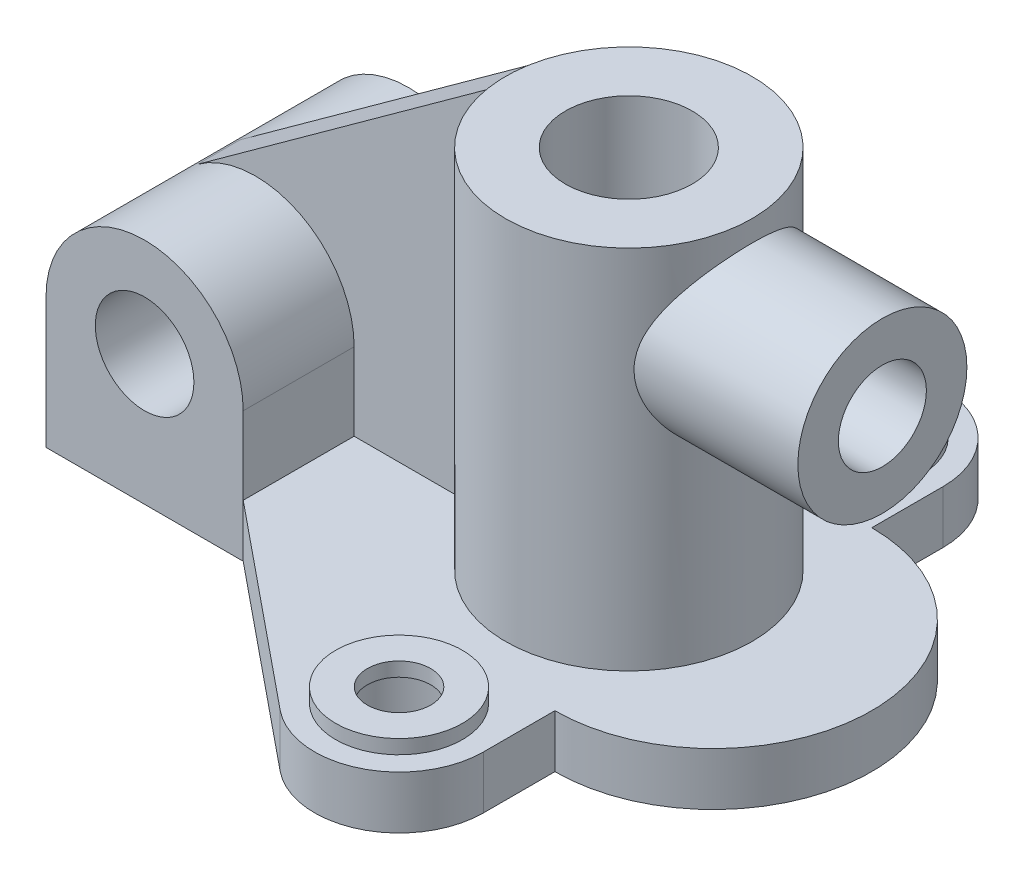
from build123d import *

# Parameters (mm, degrees)
SKETCH1_R             = 18
BOSS_EXTRUDE1_DEPTH   = 15
SKETCH2_R             = 18
SKETCH2_R_2           = 9
BOSS_EXTRUDE2_DEPTH   = 4
BOSS_EXTRUDE2_2_DEPTH = 4
SKETCH3_R             = 35
SKETCH3_R_2           = 18
BOSS_EXTRUDE3_DEPTH   = 104
SKETCH4_R             = 14
BOSS_EXTRUDE4_DEPTH   = 75
SKETCH6_R             = 24
SKETCH6_R_2           = 12.5
BOSS_EXTRUDE5_DEPTH   = 72
SKETCH9_R             = 18
CUT_EXTRUDE2_DEPTH    = 213.674418186
RIB1_REACH            = 214.674
SKETCH17_WALL_W       = 526.407388692
SKETCH17_WALL_H       = 12


with BuildPart() as part:
    # Sketch1 → Boss-Extrude1 (new body)
    with BuildSketch(Plane(origin=(0, 0, 0), x_dir=(1, 0, 0), z_dir=(0, 1, 0))):
        with BuildLine():
            Line((0, -45), (0, -65.249135293))
            ThreePointArc((0, -65.249135293), (-13.705250772, -86.929037007), (-39.168178194, -83.848231247))
            Line((-39.168178194, -83.848231247), (-96, -37.5))
            Line((-96, -37.5), (-152, -37.5))
            Line((-152, -37.5), (-152, 37.5))
            Line((-152, 37.5), (-96, 37.5))
            Line((-96, 37.5), (-39.168178194, 83.848231247))
            ThreePointArc((-39.168178194, 83.848231247), (-13.705250772, 86.929037007), (0, 65.249135293))
            Line((0, 65.249135293), (0, 45))
            ThreePointArc((0, 45), (45, 0), (0, -45))
        make_face()
        with Locations(Location((-24, 65.249135293, 0), (0, 0, 270))):
            Circle(SKETCH1_R, mode=Mode.SUBTRACT)
        with Locations(Location((-24, -65.249135293, 0), (0, 0, 270))):
            Circle(SKETCH1_R, mode=Mode.SUBTRACT)
    extrude(amount=BOSS_EXTRUDE1_DEPTH)

    # Sketch3 → Boss-Extrude3 (add)
    with BuildSketch(Plane(origin=(0, 15, 0), x_dir=(1, 0, 0), z_dir=(0, 1, 0))):
        with Locations(Location((-24, 0, 0), (0, 0, 270))):
            Circle(SKETCH3_R)
        with Locations(Location((-24, 0, 0), (0, 0, 270))):
            Circle(SKETCH3_R_2, mode=Mode.SUBTRACT)
    extrude(amount=BOSS_EXTRUDE3_DEPTH)

    # Sketch4 → Boss-Extrude4 (add)
    with BuildSketch(Plane.XY.offset(37.5)):
        with BuildLine():
            Line((-96, 15), (-96, 37))
            ThreePointArc((-96, 37), (-124, 65), (-152, 37))
            Line((-152, 37), (-152, 15))
            Line((-152, 15), (-96, 15))
        make_face()
        with Locations((-124, 37)):
            Circle(SKETCH4_R, mode=Mode.SUBTRACT)
    extrude(amount=-BOSS_EXTRUDE4_DEPTH)

    # Sketch6 → Boss-Extrude5 (add)
    with BuildSketch(Plane(origin=(-24, 0, 0), x_dir=(0, 0, -1), z_dir=(1, 0, 0))):
        with Locations(Location((0, 89, 0), (0, 0, 180))):
            Circle(SKETCH6_R)
        with Locations(Location((0, 89, 0), (0, 0, 180))):
            Circle(SKETCH6_R_2, mode=Mode.SUBTRACT)
    extrude(amount=BOSS_EXTRUDE5_DEPTH)

    # Sketch9 → Cut-Extrude2 (cut, through all)
    with BuildSketch(Plane(origin=(0, 119, 0), x_dir=(1, 0, 0), z_dir=(0, 1, 0))):
        with Locations(Location((-24, 0, 0), (0, 0, 270))):
            Circle(SKETCH9_R)
    extrude(amount=-CUT_EXTRUDE2_DEPTH, mode=Mode.SUBTRACT)

    # Sketch17 wall → Rib1 (add, up to next)
    with BuildSketch(Plane(origin=(-99.129265772, 89.551140917, 0), x_dir=(-0.810213048284, -0.586135493202, 0), z_dir=(0.586135493202, -0.810213048284, 0)), mode=Mode.PRIVATE) as rib1_sk1:
        Rectangle(SKETCH17_WALL_W, SKETCH17_WALL_H)
    rib1_tool1 = extrude(rib1_sk1.sketch, amount=RIB1_REACH, mode=Mode.PRIVATE) - part.part
    add(rib1_tool1.solids().sort_by_distance((-99.129265772, 89.551140917, 0))[0])


with BuildPart() as body_2:
    # Sketch2 → Boss-Extrude2 (new body)
    with BuildSketch(Plane(origin=(0, 15, 0), x_dir=(1, 0, 0), z_dir=(0, 1, 0))):
        with Locations(Location((-24, 65.249135293, 0), (0, 0, 270))):
            Circle(SKETCH2_R)
        with Locations(Location((-24, 65.249135293, 0), (0, 0, 270))):
            Circle(SKETCH2_R_2, mode=Mode.SUBTRACT)
    extrude(amount=BOSS_EXTRUDE2_DEPTH)


with BuildPart() as body_3:
    # Sketch2 → Boss-Extrude2 2 (new body)
    with BuildSketch(Plane(origin=(0, 15, 0), x_dir=(1, 0, 0), z_dir=(0, 1, 0))):
        with Locations(Location((-24, -65.249135293, 0), (0, 0, 270))):
            Circle(SKETCH2_R)
        with Locations(Location((-24, -65.249135293, 0), (0, 0, 270))):
            Circle(SKETCH2_R_2, mode=Mode.SUBTRACT)
    extrude(amount=BOSS_EXTRUDE2_2_DEPTH)


solid = Compound([part.part, body_2.part, body_3.part])
